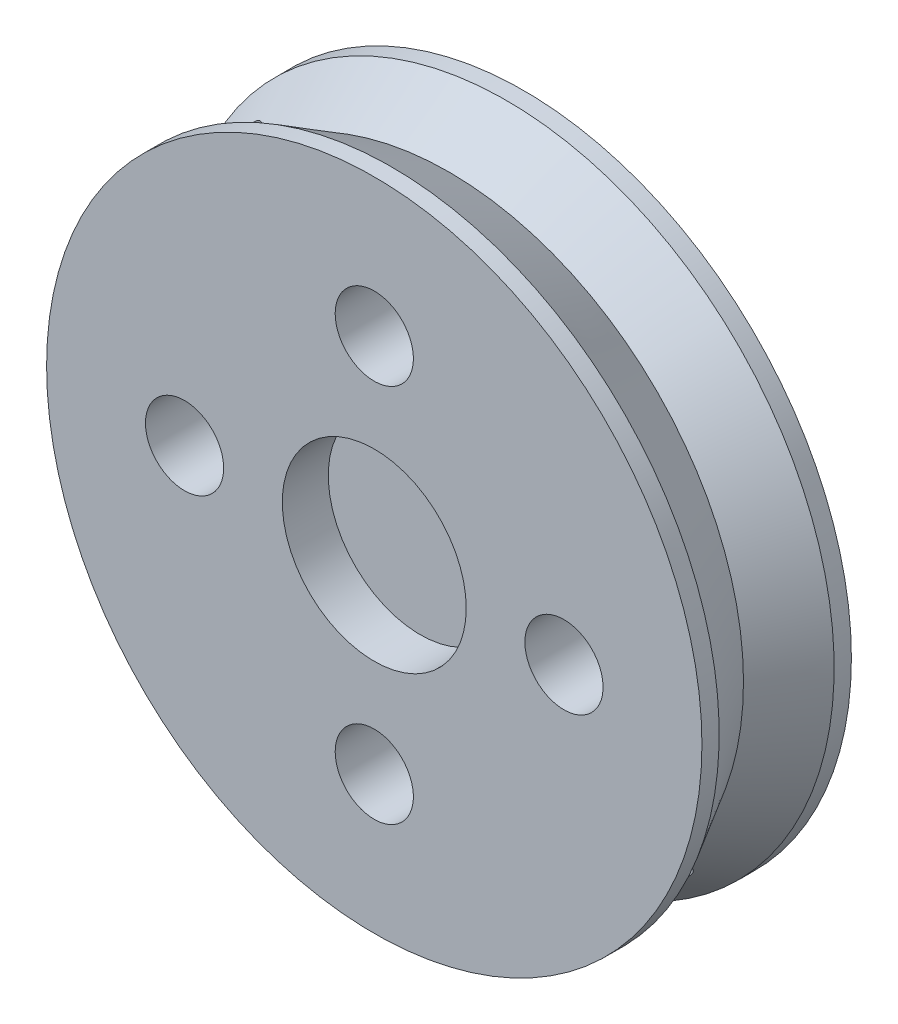
from build123d import *

# Parameters (mm, degrees)
ESQUISSE2_R                  = 14.25
BOSS_EXTRU_1_DEPTH           = 3.25
ESQUISSE3_R                  = 1.2
ENL_V_MAT_EXTRU_1_DEPTH      = 4.25
ESQUISSE10_R                 = 1.7
ENL_V_MAT_EXTRU_2_DEPTH      = 1
ENL_V_MAT_EXTRU_2_DEPTH_BACK = 7.5
ESQUISSE17_R                 = 4
ENL_V_MAT_EXTRU_8_DEPTH      = 2
ESQUISSE13_R                 = 1
ENL_V_MAT_EXTRU_4_DEPTH      = 35.402543264


with BuildPart() as part:
    # Esquisse2 → Boss.-Extru.1 (new body, symmetric)
    with BuildSketch(Plane.XY):
        Circle(ESQUISSE2_R)
    extrude(amount=BOSS_EXTRU_1_DEPTH, both=True)

    # Esquisse3 → Enlèv. mat.-Extru.1 (cut, through all)
    with BuildSketch(Plane.XY):
        with Locations((0, 8.25)):
            Circle(ESQUISSE3_R)
        with Locations((-8.25, 0)):
            Circle(ESQUISSE3_R)
        with Locations((0, -8.25)):
            Circle(ESQUISSE3_R)
        with Locations((8.25, 0)):
            Circle(ESQUISSE3_R)
    extrude(amount=ENL_V_MAT_EXTRU_1_DEPTH, mode=Mode.SUBTRACT)

    # Esquisse10 → Enlèv. mat.-Extru.2 (cut, two sides)
    with BuildSketch(Plane(origin=(0, 0, -3.25), x_dir=(-1, 0, 0), z_dir=(0, 0, -1))) as enl_v_mat_extru_2_sk:
        with Locations((-8.25, 0)):
            Circle(ESQUISSE10_R)
        with Locations((0, 8.25)):
            Circle(ESQUISSE10_R)
        with Locations((8.25, 0)):
            Circle(ESQUISSE10_R)
        with Locations((0, -8.25)):
            Circle(ESQUISSE10_R)
    extrude(amount=ENL_V_MAT_EXTRU_2_DEPTH, mode=Mode.SUBTRACT)
    extrude(enl_v_mat_extru_2_sk.sketch, amount=-ENL_V_MAT_EXTRU_2_DEPTH_BACK, mode=Mode.SUBTRACT)

    # Esquisse17 → Enlèv. mat.-Extru.8 (cut)
    with BuildSketch(Plane.XY.offset(3.25)):
        Circle(ESQUISSE17_R)
    extrude(amount=-ENL_V_MAT_EXTRU_8_DEPTH, mode=Mode.SUBTRACT)

    # Esquisse13 → Enlèv. mat.-Extru.4 (cut, through all)
    with BuildSketch(Plane(origin=(10.076271632, -10.076271632, 0), x_dir=(-0.707106781, -0.707106781, 0), z_dir=(0.707106781, -0.707106781, 0))):
        Circle(ESQUISSE13_R)
    extrude(amount=-ENL_V_MAT_EXTRU_4_DEPTH, mode=Mode.SUBTRACT)

    # Esquisse18 → Enlèvement de matière-Révolution1 (revolve, cut)
    with BuildSketch(Plane(origin=(0, 0, 0), x_dir=(1, 0, 0), z_dir=(0, 1, 0))):
        Polygon((14.25, 2.5), (12.806624327, 0), (14.25, -2.5), align=None)
    revolve(axis=Axis((0, 0, -3.25), (0, 0, 1)), mode=Mode.SUBTRACT)


solid = part.part
